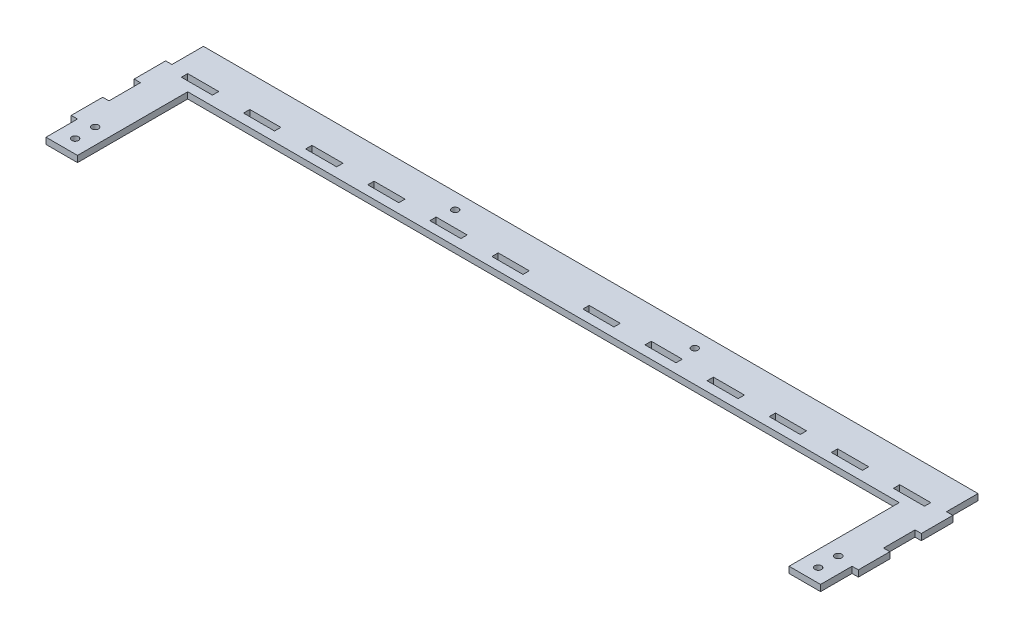
from build123d import *

# Parameters (mm, degrees)
SKETCH1_R           = 2.125
SKETCH1_W           = 19.725
SKETCH1_H           = 4
BOSS_EXTRUDE1_DEPTH = 4


with BuildPart() as part:
    # Sketch1 → Boss-Extrude1 (new body)
    with BuildSketch(Plane(origin=(0, 0, 0), x_dir=(1, 0, 0), z_dir=(0, 1, 0))):
        Polygon((4, 0), (4, 20), (0, 20), (0, 40), (4, 40), (4, 60), (0, 60), (0, 80), (4, 80), (4, 100), (250, 100), (496, 100), (496, 80), (500, 80), (500, 60), (496, 60), (496, 40), (500, 40), (500, 20), (496, 20), (496, 0), (476, 0), (476, 70), (24, 70), (24, 0), align=None)
        with Locations((14, 8.5)):
            Circle(SKETCH1_R, mode=Mode.SUBTRACT)
        with Locations((14, 21.25)):
            Circle(SKETCH1_R, mode=Mode.SUBTRACT)
        with Locations((173.885, 90)):
            Circle(SKETCH1_R, mode=Mode.SUBTRACT)
        with Locations((326.115, 90)):
            Circle(SKETCH1_R, mode=Mode.SUBTRACT)
        with Locations((486, 21.25)):
            Circle(SKETCH1_R, mode=Mode.SUBTRACT)
        with Locations((486, 8.5)):
            Circle(SKETCH1_R, mode=Mode.SUBTRACT)
        with Locations((63.3125, 78)):
            Rectangle(SKETCH1_W, SKETCH1_H, mode=Mode.SUBTRACT)
        with Locations((23.8625, 78)):
            Rectangle(SKETCH1_W, SKETCH1_H, mode=Mode.SUBTRACT)
        with Locations((102.7625, 78)):
            Rectangle(SKETCH1_W, SKETCH1_H, mode=Mode.SUBTRACT)
        with Locations((142.2125, 78)):
            Rectangle(SKETCH1_W, SKETCH1_H, mode=Mode.SUBTRACT)
        with Locations((181.6625, 78)):
            Rectangle(SKETCH1_W, SKETCH1_H, mode=Mode.SUBTRACT)
        with Locations((221.1125, 78)):
            Rectangle(SKETCH1_W, SKETCH1_H, mode=Mode.SUBTRACT)
        with Locations((278.8875, 78)):
            Rectangle(SKETCH1_W, SKETCH1_H, mode=Mode.SUBTRACT)
        with Locations((318.3375, 78)):
            Rectangle(SKETCH1_W, SKETCH1_H, mode=Mode.SUBTRACT)
        with Locations((357.7875, 78)):
            Rectangle(SKETCH1_W, SKETCH1_H, mode=Mode.SUBTRACT)
        with Locations((397.2375, 78)):
            Rectangle(SKETCH1_W, SKETCH1_H, mode=Mode.SUBTRACT)
        with Locations((436.6875, 78)):
            Rectangle(SKETCH1_W, SKETCH1_H, mode=Mode.SUBTRACT)
        with Locations((476.1375, 78)):
            Rectangle(SKETCH1_W, SKETCH1_H, mode=Mode.SUBTRACT)
    extrude(amount=BOSS_EXTRUDE1_DEPTH)


solid = part.part
